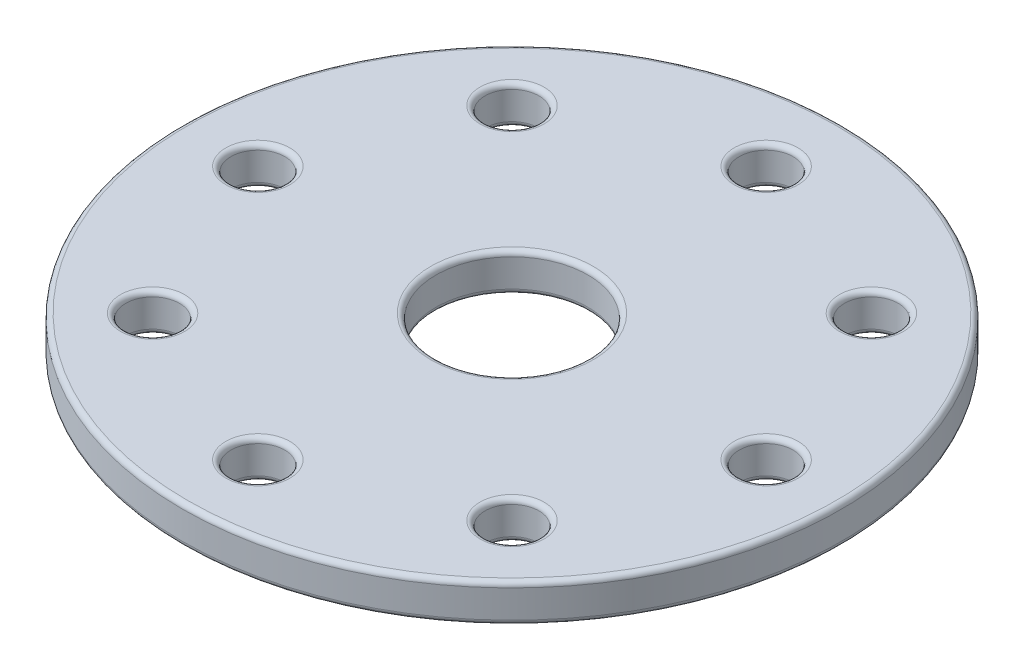
from build123d import *

# Parameters (mm, degrees)
SKETCH2_R               = 32.5
BOSS_EXTRUDE1_DEPTH     = 1.875
SKETCH3_R               = 7.5
CUT_EXTRUDE1_DEPTH      = 2.875
CUT_EXTRUDE1_DEPTH_BACK = 2.875
SKETCH4_R               = 2.65625
CUT_EXTRUDE2_DEPTH      = 2.875
CIRPATTERN1_COUNT       = 8
FILLET1_R               = 0.5


with BuildPart() as part:
    # Sketch2 → Boss-Extrude1 (new body, symmetric)
    with BuildSketch(Plane(origin=(0, 0, 0), x_dir=(1, 0, 0), z_dir=(0, 1, 0))):
        Circle(SKETCH2_R)
    extrude(amount=BOSS_EXTRUDE1_DEPTH, both=True)

    # Sketch3 → Cut-Extrude1 (cut, two sides)
    with BuildSketch(Plane(origin=(0, 0, 0), x_dir=(1, 0, 0), z_dir=(0, 1, 0))) as cut_extrude1_sk:
        Circle(SKETCH3_R)
    extrude(amount=CUT_EXTRUDE1_DEPTH, mode=Mode.SUBTRACT)
    extrude(cut_extrude1_sk.sketch, amount=-CUT_EXTRUDE1_DEPTH_BACK, mode=Mode.SUBTRACT)

    # Sketch4 → Cut-Extrude2 (cut, symmetric)
    with BuildSketch(Plane(origin=(0, 0, 0), x_dir=(1, 0, 0), z_dir=(0, 1, 0))):
        with Locations((0, 25.0625)):
            Circle(SKETCH4_R)
    cut_extrude2 = extrude(amount=CUT_EXTRUDE2_DEPTH, both=True, mode=Mode.SUBTRACT)

    # CirPattern1: Cut-Extrude2 ×8 about axis
    cirpattern1_axis = Axis((0, 0, 0), (0, 1, 0))
    for i in range(1, CIRPATTERN1_COUNT):
        add(cut_extrude2.rotate(cirpattern1_axis, i * 360 / CIRPATTERN1_COUNT), mode=Mode.SUBTRACT)

    # Fillet1
    fillet1_edges = [part.edges().sort_by_distance(p)[0] for p in [
        (-2.65625, -1.875, -25.0625),
        (-2.65625, 1.875, -25.0625),
        (-32.5, -1.875, 0),
        (-25.0625, -1.875, 2.65625),
        (-25.0625, 1.875, 2.65625),
        (-15.843611316, -1.875, 19.600116091),
        (-15.843611316, 1.875, 19.600116091),
        (2.65625, -1.875, 25.0625),
        (2.65625, 1.875, 25.0625),
        (19.600116091, -1.875, 15.843611316),
        (19.600116091, 1.875, 15.843611316),
        (25.0625, -1.875, -2.65625),
        (25.0625, 1.875, -2.65625),
        (15.843611316, -1.875, -19.600116091),
        (15.843611316, 1.875, -19.600116091),
        (-19.600116091, -1.875, -15.843611316),
        (-19.600116091, 1.875, -15.843611316),
        (-32.5, 1.875, 0),
        (-7.5, -1.875, 0),
        (-7.5, 1.875, 0),
    ]]
    fillet(fillet1_edges, radius=FILLET1_R)


solid = part.part
